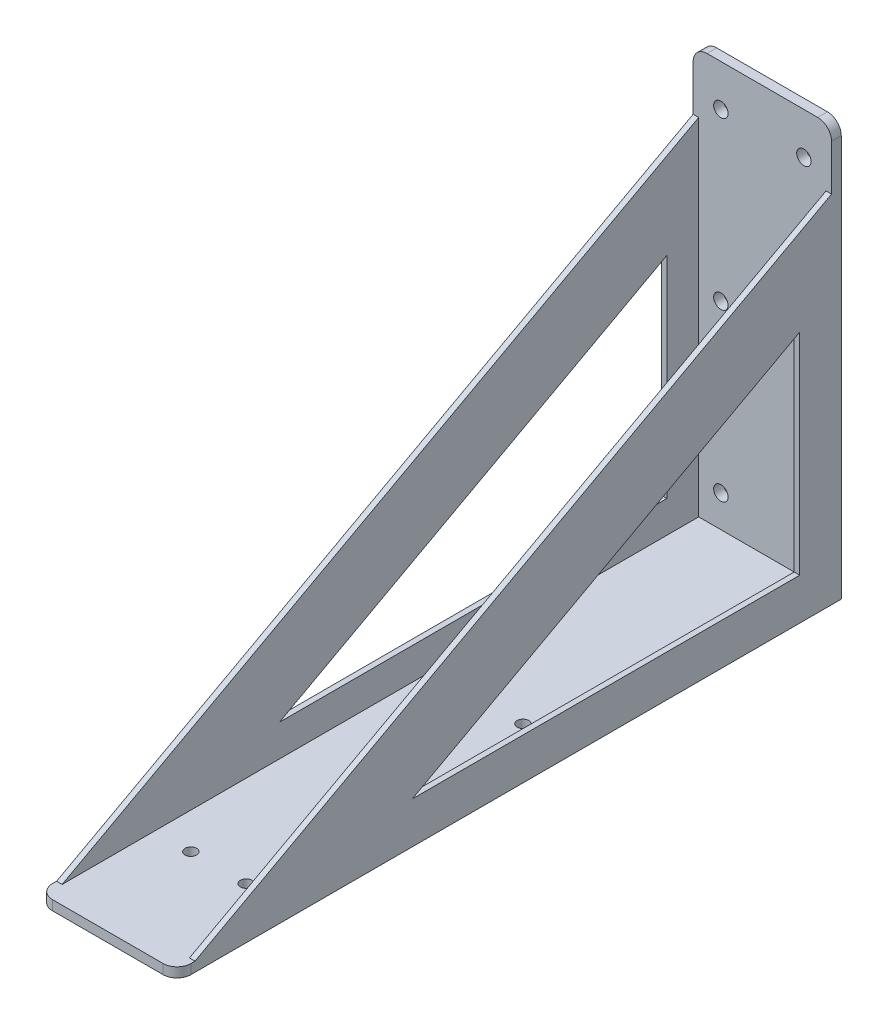
from build123d import *

# Parameters (mm, degrees)
EXTRUDE_1_DEPTH     = 25
SKETCH_4_R          = 2.6
CUT_EXTRUDE_2_DEPTH = 241
FILLET_1_R          = 5
FILLET_2_R          = 5
SKETCH_5_R          = 2.1
CUT_EXTRUDE_3_DEPTH = 151
EXTRUDE_2_DEPTH     = 2
EXTRUDE_3_DEPTH     = 2
CUT_EXTRUDE_4_DEPTH = 51


with BuildPart() as part:
    # 草图1 → 凸台-拉伸1 (new body, symmetric)
    with BuildSketch(Plane(origin=(0, 0, 0), x_dir=(0, 0, -1), z_dir=(1, 0, 0))):
        Polygon((-240, 0), (0, 0), (0, 150), (-3.5, 150), (-3.5, 3.5), (-240, 3.5), align=None)
    extrude(amount=EXTRUDE_1_DEPTH, both=True)

    # 草图4 → 切除-拉伸2 (cut, through all)
    with BuildSketch(Plane(origin=(0, 0, 0), x_dir=(-1, 0, 0), z_dir=(0, 0, -1))):
        with Locations((-15, 135)):
            Circle(SKETCH_4_R)
        with Locations((15, 135)):
            Circle(SKETCH_4_R)
        with Locations((15, 15)):
            Circle(SKETCH_4_R)
        with Locations((-15, 15)):
            Circle(SKETCH_4_R)
        with Locations((-15, 75)):
            Circle(SKETCH_4_R)
        with Locations((15, 75)):
            Circle(SKETCH_4_R)
    extrude(amount=-CUT_EXTRUDE_2_DEPTH, mode=Mode.SUBTRACT)

    # 圆角1
    fillet_1_edges = [part.edges().sort_by_distance(p)[0] for p in [
        (25, 1.75, 240),
        (-25, 1.75, 240),
    ]]
    fillet(fillet_1_edges, radius=FILLET_1_R)

    # 圆角2
    fillet_2_edges = [part.edges().sort_by_distance(p)[0] for p in [
        (25, 150, 1.75),
        (-25, 150, 1.75),
    ]]
    fillet(fillet_2_edges, radius=FILLET_2_R)

    # 草图5 → 切除-拉伸3 (cut, through all)
    with BuildSketch(Plane.XZ):
        with Locations((-10, 200)):
            Circle(SKETCH_5_R)
        with Locations((-10, 100)):
            Circle(SKETCH_5_R)
        with Locations((10, 100)):
            Circle(SKETCH_5_R)
        with Locations((10, 200)):
            Circle(SKETCH_5_R)
    extrude(amount=-CUT_EXTRUDE_3_DEPTH, mode=Mode.SUBTRACT)

    # 草图8 → 凸台-拉伸2 (add)
    with BuildSketch(Plane(origin=(25, 0, 0), x_dir=(0, 0, -1), z_dir=(1, 0, 0))):
        Polygon((-3.5, 3.5), (-233.5, 3.5), (-3.5, 128.5), align=None)
    extrude(amount=-EXTRUDE_2_DEPTH)

    # 草图9 → 凸台-拉伸3 (add)
    with BuildSketch(Plane.ZY.offset(25)):
        Polygon((3.5, 3.5), (233.5, 3.5), (3.5, 128.5), align=None)
    extrude(amount=-EXTRUDE_3_DEPTH)

    # 草图10 → 切除-拉伸4 (cut, through all)
    with BuildSketch(Plane.ZY.offset(25)):
        Polygon((15, 91.086956522), (15, 15), (155, 15), align=None)
    extrude(amount=-CUT_EXTRUDE_4_DEPTH, mode=Mode.SUBTRACT)


solid = part.part
